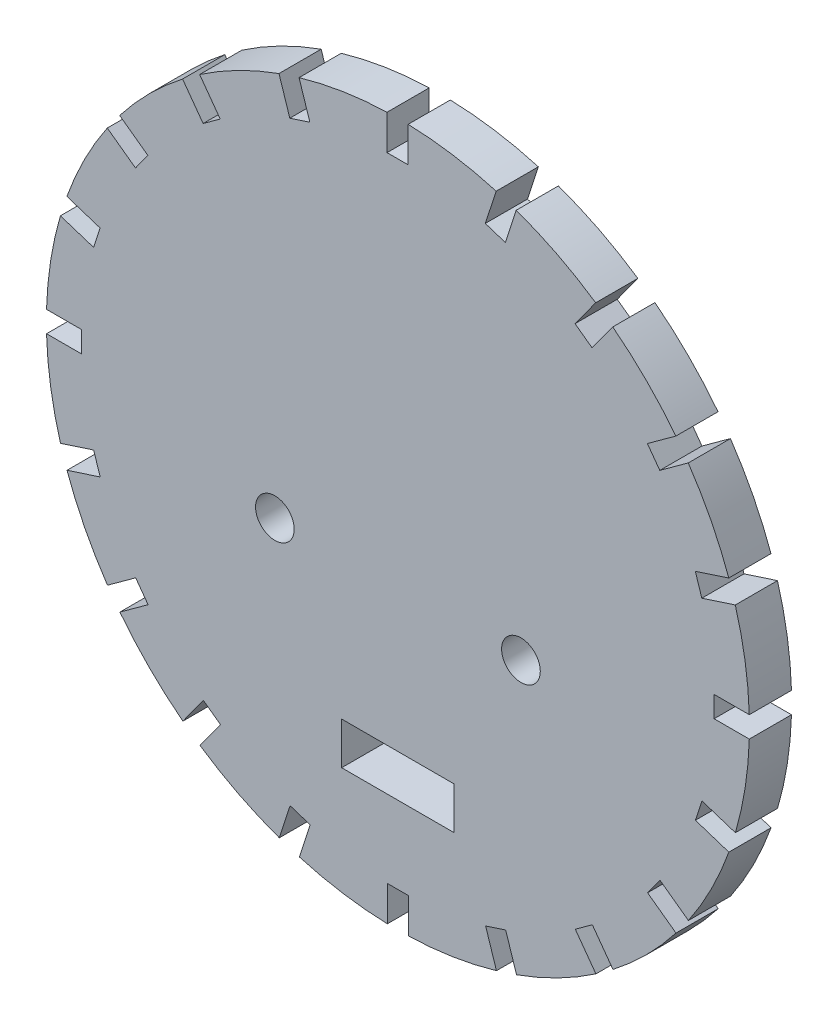
from build123d import *

# Parameters (mm, degrees)
SKETCH2_W           = 16
SKETCH2_H           = 6
SKETCH2_R           = 2.75
BOSS_EXTRUDE1_DEPTH = 6
SKETCH3_R           = 5.25
CUT_EXTRUDE1_DEPTH  = 1.5


with BuildPart() as part:
    # Sketch2 → Boss-Extrude1 (new body)
    with BuildSketch(Plane.XY):
        with BuildLine():
            ThreePointArc((-14.014958559, -48.70381072), (-7.820513245, -50.092784824), (-1.5, -50.685671098))
            Line((-1.5, -50.685671098), (-1.5, -45.708176163))
            Line((-1.5, -45.708176163), (1.5, -45.708176163))
            Line((1.5, -45.708176163), (1.5, -50.685671098))
            ThreePointArc((1.5, -50.685671098), (7.821643905, -50.09260576), (14.017156267, -48.703168924))
            Line((14.017156267, -48.703168924), (12.476730902, -43.962227135))
            Line((12.476730902, -43.962227135), (15.32990045, -43.035176152))
            Line((15.32990045, -43.035176152), (16.870328795, -47.776127109))
            ThreePointArc((16.870328795, -47.776127109), (22.700337229, -45.258088505), (28.164148211, -42.021379325))
            Line((28.164148211, -42.021379325), (25.229863981, -37.982683562))
            Line((25.229863981, -37.982683562), (27.656914964, -36.219327805))
            Line((27.656914964, -36.219327805), (30.591129228, -40.257927268))
            ThreePointArc((30.591129228, -40.257927268), (35.358240772, -36.060613271), (39.55477218, -31.292812793))
            Line((39.55477218, -31.292812793), (35.511033717, -28.354864828))
            Line((35.511033717, -28.354864828), (37.274389474, -25.927813845))
            Line((37.274389474, -25.927813845), (41.317825829, -28.865542317))
            ThreePointArc((41.317825829, -28.865542317), (44.554494815, -23.399517942), (47.071992795, -17.567224011))
            Line((47.071992795, -17.567224011), (42.313847582, -16.021208913))
            Line((42.313847582, -16.021208913), (43.240898565, -13.168039364))
            Line((43.240898565, -13.168039364), (47.998350807, -14.713829302))
            ThreePointArc((47.998350807, -14.713829302), (49.386863483, -8.514437454), (49.978066205, -2.189019992))
            Line((49.978066205, -2.189019992), (44.972398757, -2.189019992))
            Line((44.972398757, -2.189019992), (44.972398757, 0.810980008))
            Line((44.972398757, 0.810980008), (49.976916317, 0.810980008))
            ThreePointArc((49.976916317, 0.810980008), (49.380832331, 7.136146516), (47.987483994, 13.334664716))
            Line((47.987483994, 13.334664716), (43.22644973, 11.787710909))
            Line((43.22644973, 11.787710909), (42.299398746, 14.640880458))
            Line((42.299398746, 14.640880458), (47.058915168, 16.187341088))
            ThreePointArc((47.058915168, 16.187341088), (44.536626084, 22.0182168), (41.295318935, 27.482188044))
            Line((41.295318935, 27.482188044), (37.246906156, 24.540843989))
            Line((37.246906156, 24.540843989), (35.483550399, 26.967894972))
            Line((35.483550399, 26.967894972), (39.530326401, 29.908049839))
            ThreePointArc((39.530326401, 29.908049839), (35.329326435, 34.673156396), (30.558045552, 38.86714256))
            Line((30.558045552, 38.86714256), (27.619087422, 34.822013725))
            Line((27.619087422, 34.822013725), (25.192036439, 36.585369482))
            Line((25.192036439, 36.585369482), (28.129589934, 40.628565002))
            ThreePointArc((28.129589934, 40.628565002), (22.66202489, 43.861237429), (16.828745179, 46.374658668))
            Line((16.828745179, 46.374658668), (15.285431508, 41.62482759))
            Line((15.285431508, 41.62482759), (12.432261959, 42.551878573))
            Line((12.432261959, 42.551878573), (13.974753738, 47.299180128))
            ThreePointArc((13.974753738, 47.299180128), (7.776727495, 48.683346485), (1.453242586, 49.270700235))
            Line((1.453242586, 49.270700235), (1.453242586, 44.283378765))
            Line((1.453242586, 44.283378765), (-1.546757414, 44.283378765))
            Line((-1.546757414, 44.283378765), (-1.546757414, 49.2608737))
            ThreePointArc((-1.546757414, 49.2608737), (-7.866904098, 48.661958763), (-14.060191394, 47.266915506))
            Line((-14.060191394, 47.266915506), (-12.523488315, 42.537429737))
            Line((-12.523488315, 42.537429737), (-15.376657864, 41.610378754))
            Line((-15.376657864, 41.610378754), (-16.914659767, 46.343861891))
            ThreePointArc((-16.914659767, 46.343861891), (-22.740383136, 43.821308169), (-28.199510335, 40.580897657))
            Line((-28.199510335, 40.580897657), (-25.276621395, 36.557886164))
            Line((-25.276621395, 36.557886164), (-27.703672378, 34.794530407))
            Line((-27.703672378, 34.794530407), (-30.624981542, 38.815367524))
            ThreePointArc((-30.624981542, 38.815367524), (-35.385501758, 34.616974444), (-39.575762572, 29.849294558))
            Line((-39.575762572, 29.849294558), (-35.557791131, 26.93006743))
            Line((-35.557791131, 26.93006743), (-37.321146887, 24.503016447))
            Line((-37.321146887, 24.503016447), (-41.33714976, 27.420813327))
            ThreePointArc((-41.33714976, 27.420813327), (-44.567381262, 21.957845266), (-47.079571363, 16.129696634))
            Line((-47.079571363, 16.129696634), (-42.360604995, 14.596411515))
            Line((-42.360604995, 14.596411515), (-43.287655979, 11.743241967))
            Line((-43.287655979, 11.743241967), (-48.004645978, 13.275884924))
            ThreePointArc((-48.004645978, 13.275884924), (-49.389276358, 7.082804571), (-49.978315717, 0.764222594))
            Line((-49.978315717, 0.764222594), (-45.01915617, 0.764222594))
            Line((-45.01915617, 0.764222594), (-45.01915617, -2.235777406))
            Line((-45.01915617, -2.235777406), (-49.976658896, -2.235777406))
            ThreePointArc((-49.976658896, -2.235777406), (-49.380673152, -8.553500826), (-47.989286669, -14.744855434))
            Line((-47.989286669, -14.744855434), (-43.273207143, -13.212508307))
            Line((-43.273207143, -13.212508307), (-42.34615616, -16.065677856))
            Line((-42.34615616, -16.065677856), (-47.06108419, -17.597650839))
            ThreePointArc((-47.06108419, -17.597650839), (-44.542778803, -23.422507686), (-41.306963736, -28.881474636))
            Line((-41.306963736, -28.881474636), (-37.293663569, -25.965641387))
            Line((-37.293663569, -25.965641387), (-35.530307812, -28.39269237))
            Line((-35.530307812, -28.39269237), (-39.542974081, -31.308065065))
            ThreePointArc((-39.542974081, -31.308065065), (-35.348264075, -36.07058879), (-30.584062086, -40.263392586))
            Line((-30.584062086, -40.263392586), (-27.665844836, -36.246811123))
            Line((-27.665844836, -36.246811123), (-25.238793853, -38.01016688))
            Line((-25.238793853, -38.01016688), (-28.156765996, -42.026410983))
            ThreePointArc((-28.156765996, -42.026410983), (-22.695337069, -45.260635975), (-16.868173537, -47.776899552))
            Line((-16.868173537, -47.776899552), (-15.332188921, -43.049624988))
            Line((-15.332188921, -43.049624988), (-12.479019372, -43.976675971))
            Line((-12.479019372, -43.976675971), (-14.014958559, -48.70381072))
        make_face()
        with Locations((0, -31.708176163)):
            Rectangle(SKETCH2_W, SKETCH2_H, mode=Mode.SUBTRACT)
        with Locations((-17.5, -8.708176163)):
            Circle(SKETCH2_R, mode=Mode.SUBTRACT)
        with Locations((17.5, -8.708176163)):
            Circle(SKETCH2_R, mode=Mode.SUBTRACT)
    extrude(amount=BOSS_EXTRUDE1_DEPTH)

    # Sketch3 → Cut-Extrude1 (cut)
    with BuildSketch(Plane(origin=(0, 0, 0), x_dir=(-1, 0, 0), z_dir=(0, 0, -1))):
        with Locations((-17.5, -8.708176163)):
            Circle(SKETCH3_R)
        with Locations((17.5, -8.708176163)):
            Circle(SKETCH3_R)
    extrude(amount=-CUT_EXTRUDE1_DEPTH, mode=Mode.SUBTRACT)


solid = part.part
